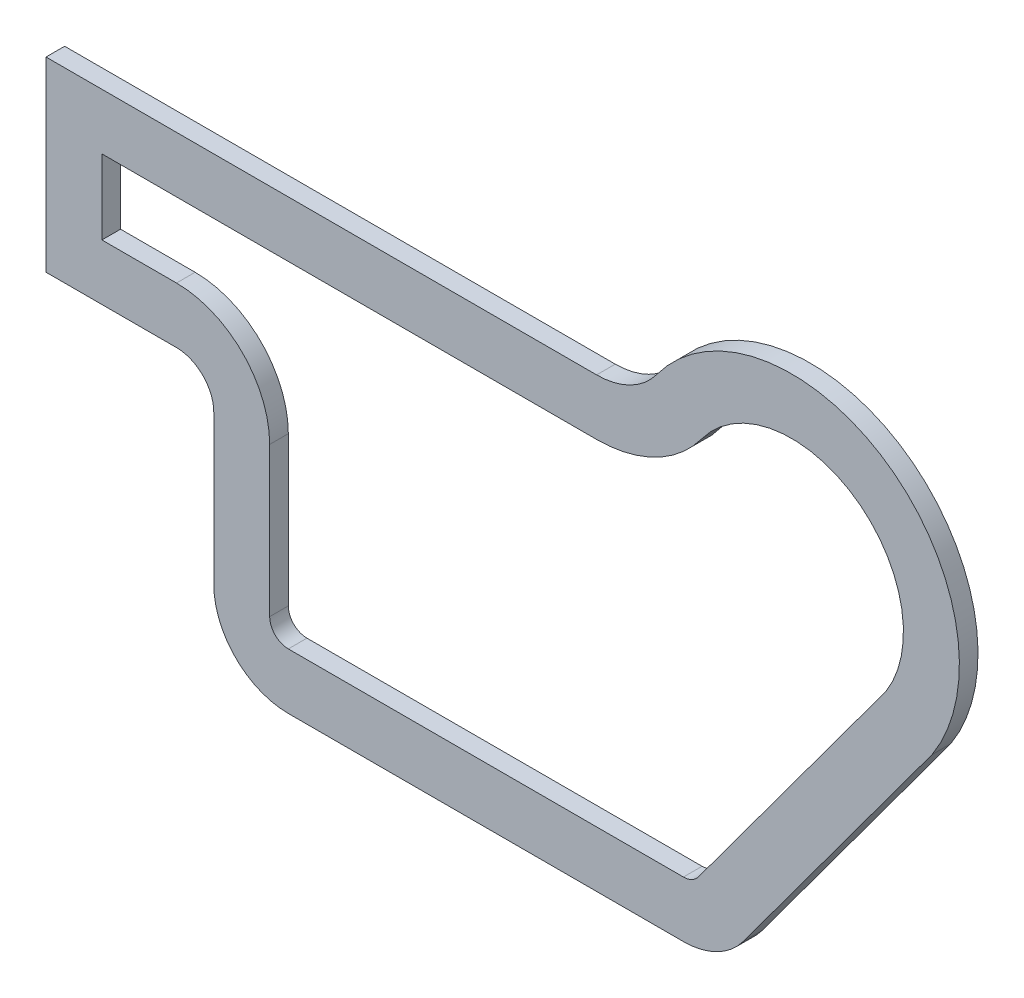
from build123d import *

# Parameters (mm, degrees)
BOSS_EXTRUDE1_DEPTH = 5


with BuildPart() as part:
    # Sketch2 → Boss-Extrude1 (new body)
    with BuildSketch(Plane.XY):
        with BuildLine():
            Line((0, 0), (0, 50))
            Line((0, 50), (147.694165659, 50))
            ThreePointArc((147.694165659, 50), (156.708879353, 52.146850782), (163.788268533, 58.126506299))
            ThreePointArc((163.788268533, 58.126506299), (225.679200393, 68.364882321), (237.666102591, 6.788702139))
            Line((237.666102591, 6.788702139), (187.081159294, -61.863810699))
            ThreePointArc((187.081159294, -61.863810699), (180, -67.850437165), (170.979917239, -70))
            Line((170.979917239, -70), (65, -70))
            ThreePointArc((65, -70), (50.857864376, -64.142135624), (45, -50))
            Line((45, -50), (45, -10))
            ThreePointArc((45, -10), (42.071067812, -2.928932188), (35, 0))
            Line((35, 0), (0, 0))
        make_face()
        with BuildLine():
            Line((15, 35), (147.694165659, 35))
            ThreePointArc((147.694165659, 35), (163.469914624, 38.756988868), (175.858845689, 49.221386023))
            ThreePointArc((175.858845689, 49.221386023), (216.96392633, 56.154330461), (225.315559898, 15.313865357))
            Line((225.315559898, 15.313865357), (175.005227753, -52.965952675))
            ThreePointArc((175.005227753, -52.965952675), (173.23493793, -54.462609291), (170.979917239, -55))
            Line((170.979917239, -55), (65, -55))
            ThreePointArc((65, -55), (61.464466094, -53.535533906), (60, -50))
            Line((60, -50), (60, -10))
            ThreePointArc((60, -10), (52.67766953, 7.67766953), (35, 15))
            Line((35, 15), (15, 15))
            Line((15, 15), (15, 35))
        make_face(mode=Mode.SUBTRACT)
    extrude(amount=BOSS_EXTRUDE1_DEPTH)


solid = part.part
